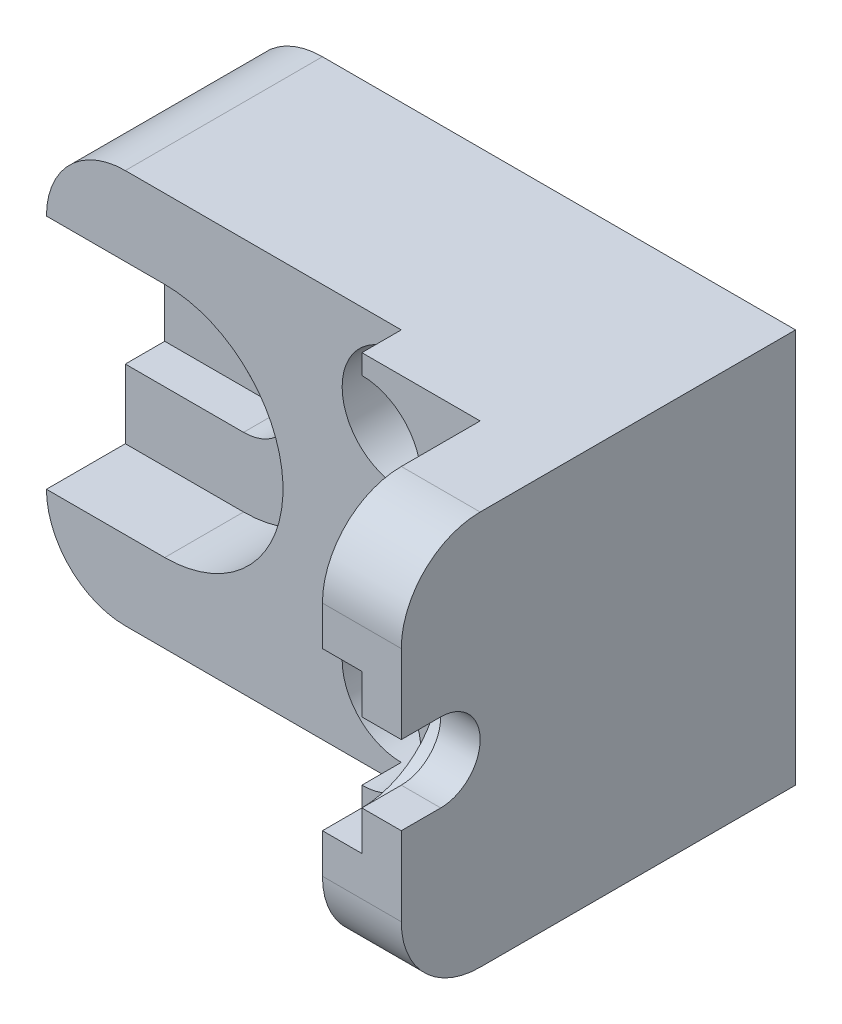
from build123d import *

# Parameters (mm, degrees)
SKETCH1_R           = 1.25
SKETCH1_R_2         = 0.5
BOSS_EXTRUDE1_DEPTH = 6
BOSS_EXTRUDE2_DEPTH = 2
CUT_EXTRUDE1_DEPTH  = 1
CUT_EXTRUDE2_DEPTH  = 1
CUT_EXTRUDE3_DEPTH  = 2
CUT_EXTRUDE4_DEPTH  = 1
SKETCH9_R           = 1.5
CUT_EXTRUDE5_DEPTH  = 3


with BuildPart() as part:
    # Sketch1 → Boss-Extrude1 (new body)
    with BuildSketch(Plane.XY):
        with BuildLine():
            Line((2, 0), (14, 0))
            Line((14, 0), (14, 10))
            Line((14, 10), (2, 10))
            ThreePointArc((2, 10), (0.585786438, 9.414213562), (0, 8))
            Line((0, 8), (0, 2))
            ThreePointArc((0, 2), (0.585786438, 0.585786438), (2, 0))
        make_face()
        with Locations((3, 5)):
            Circle(SKETCH1_R, mode=Mode.SUBTRACT)
        with Locations((9, 8)):
            Circle(SKETCH1_R_2, mode=Mode.SUBTRACT)
        with Locations((9, 2)):
            Circle(SKETCH1_R_2, mode=Mode.SUBTRACT)
    extrude(amount=BOSS_EXTRUDE1_DEPTH)

    # Sketch2 → Boss-Extrude2 (add)
    with BuildSketch(Plane(origin=(14, 0, 0), x_dir=(0, 0, -1), z_dir=(1, 0, 0))):
        with BuildLine():
            Line((-6, 0), (-6, 10))
            Line((-6, 10), (-8, 10))
            ThreePointArc((-8, 10), (-9.414213562, 9.414213562), (-10, 8))
            Line((-10, 8), (-10, 7))
            Line((-10, 7), (-9, 7))
            ThreePointArc((-9, 7), (-7, 5), (-9, 3))
            Line((-9, 3), (-10, 3))
            Line((-10, 3), (-10, 2))
            ThreePointArc((-10, 2), (-9.414213562, 0.585786438), (-8, 0))
            Line((-8, 0), (-6, 0))
        make_face()
        with BuildLine():
            Line((-9, 7), (-10, 7))
            Line((-10, 7), (-10, 6))
            Line((-10, 6), (-9, 6))
            ThreePointArc((-9, 6), (-8, 5), (-9, 4))
            Line((-9, 4), (-10, 4))
            Line((-10, 4), (-10, 3))
            Line((-10, 3), (-9, 3))
            ThreePointArc((-9, 3), (-7, 5), (-9, 7))
        make_face()
    extrude(amount=-BOSS_EXTRUDE2_DEPTH)

    # Sketch5 → Cut-Extrude1 (cut)
    with BuildSketch(Plane.ZY.offset(-12)):
        with BuildLine():
            Line((9, 7), (11.167948086, 7))
            ThreePointArc((11.167948086, 7), (13.167948086, 5), (11.167948086, 3))
            Line((11.167948086, 3), (9, 3))
            ThreePointArc((9, 3), (7, 5), (9, 7))
        make_face()
    extrude(amount=-CUT_EXTRUDE1_DEPTH, mode=Mode.SUBTRACT)

    # Sketch6 → Cut-Extrude2 (cut)
    with BuildSketch(Plane.XY.offset(6)):
        with BuildLine():
            Line((9, 10.115579993), (9, 9.5))
            ThreePointArc((9, 9.5), (10.5, 8), (9, 6.5))
            Line((9, 6.5), (9, 3.5))
            ThreePointArc((9, 3.5), (10.5, 2), (9, 0.5))
            Line((9, 0.5), (9, -0.336498004))
            Line((9, -0.336498004), (-3.111242448, -0.336498004))
            Line((-3.111242448, -0.336498004), (-3.111242448, 10.115579993))
            Line((-3.111242448, 10.115579993), (9, 10.115579993))
        make_face()
    extrude(amount=-CUT_EXTRUDE2_DEPTH, mode=Mode.SUBTRACT)

    # Sketch7 → Cut-Extrude3 (cut)
    with BuildSketch(Plane.XY.offset(5)):
        with BuildLine():
            Line((3, 2), (-3.248762224, 2))
            ThreePointArc((-3.248762224, 2), (-6.248762224, 5), (-3.248762224, 8))
            Line((-3.248762224, 8), (3, 8))
            ThreePointArc((3, 8), (6, 5), (3, 2))
        make_face()
    extrude(amount=-CUT_EXTRUDE3_DEPTH, mode=Mode.SUBTRACT)

    # Sketch8 → Cut-Extrude4 (cut)
    with BuildSketch(Plane.XY.offset(3)):
        with BuildLine():
            Line((3, 3.75), (-1.562441064, 3.75))
            ThreePointArc((-1.562441064, 3.75), (-2.812441064, 5), (-1.562441064, 6.25))
            Line((-1.562441064, 6.25), (3, 6.25))
            ThreePointArc((3, 6.25), (4.25, 5), (3, 3.75))
        make_face()
    extrude(amount=-CUT_EXTRUDE4_DEPTH, mode=Mode.SUBTRACT)

    # Sketch9 → Cut-Extrude5 (cut)
    with BuildSketch(Plane.XY.offset(5)):
        with Locations((9, 8)):
            Circle(SKETCH9_R)
        with Locations((9, 2)):
            Circle(SKETCH9_R)
    extrude(amount=-CUT_EXTRUDE5_DEPTH, mode=Mode.SUBTRACT)


solid = part.part
